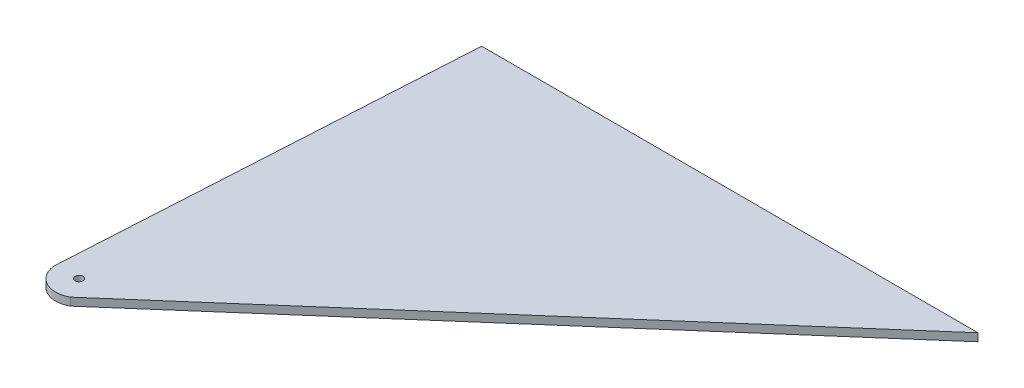
from build123d import *

# Parameters (mm, degrees)
ESQUISSE1_R        = 1
BOSS_EXTRU_2_DEPTH = 2


with BuildPart() as part:
    # Esquisse1 → Boss.-Extru.2 (new body)
    with BuildSketch(Plane(origin=(0, 0, 0), x_dir=(1, 0, 0), z_dir=(0, 1, 0))):
        with BuildLine():
            Line((0, 103), (127, 103))
            Line((127, 103), (3, -5.196152423))
            ThreePointArc((3, -5.196152423), (-3, -5.196152423), (-6, 0))
            Line((-6, 0), (0, 103))
        make_face()
        Circle(ESQUISSE1_R, mode=Mode.SUBTRACT)
    extrude(amount=BOSS_EXTRU_2_DEPTH)


solid = part.part
